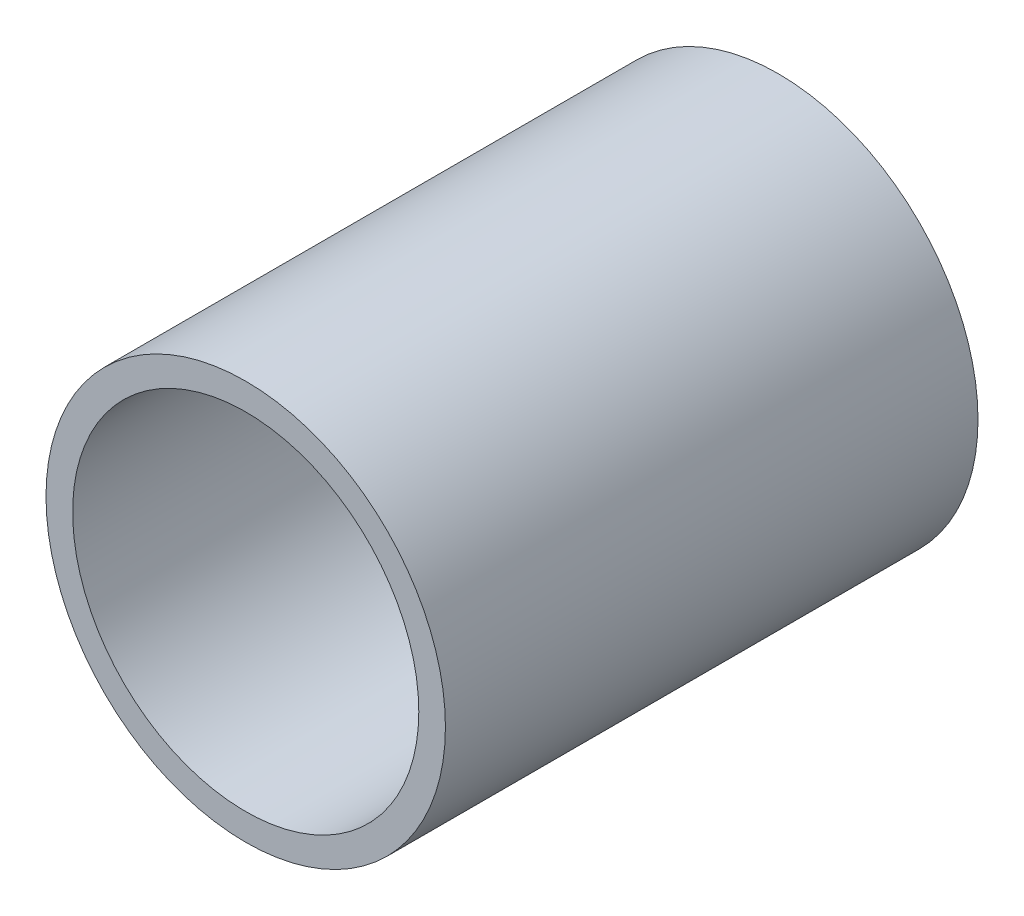
from build123d import *

# Parameters (mm, degrees)
ESBO_O1_R                = 7.5
ESBO_O1_R_2              = 6.5
RESSALTO_EXTRUS_O1_DEPTH = 20


with BuildPart() as part:
    # Esboço1 → Ressalto-extrusão1 (new body)
    with BuildSketch(Plane.XY):
        Circle(ESBO_O1_R)
        Circle(ESBO_O1_R_2, mode=Mode.SUBTRACT)
    extrude(amount=RESSALTO_EXTRUS_O1_DEPTH)


solid = part.part
